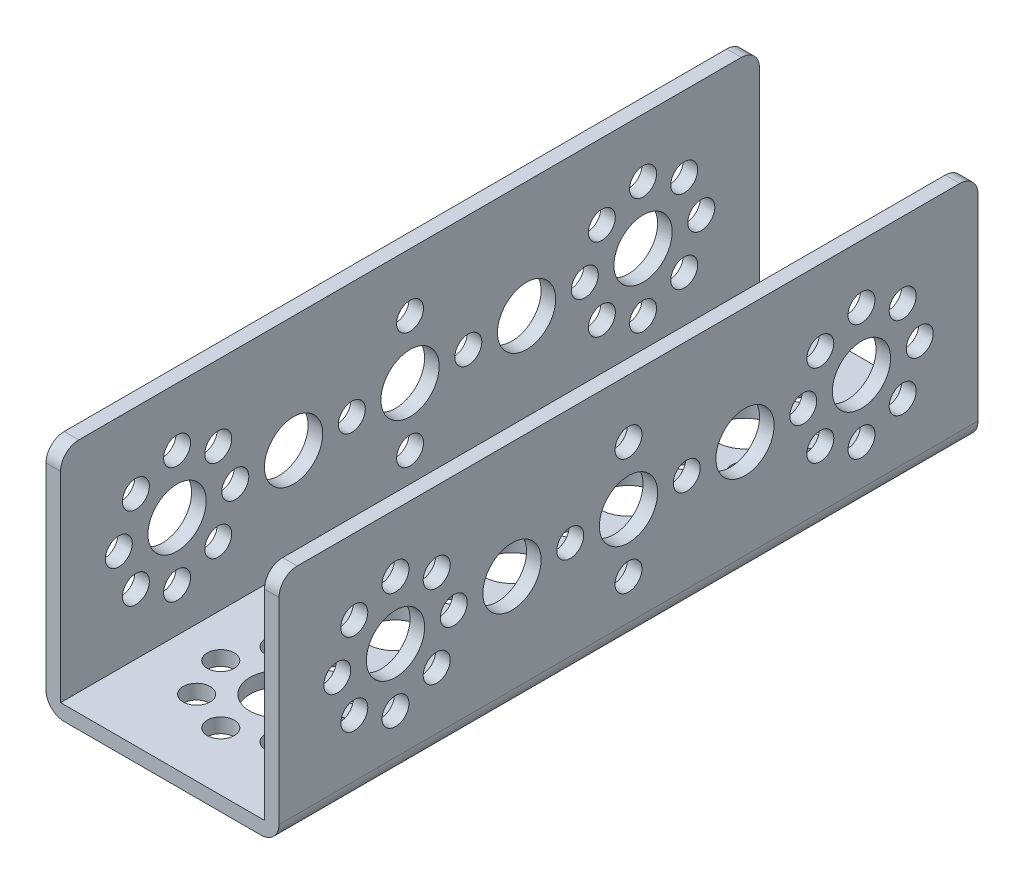
from build123d import *

# Parameters (mm, degrees)
SKETCH1_W                      = 96
SKETCH1_H                      = 32
BOSS_EXTRUDE1_DEPTH            = 32
SKETCH2_W                      = 28
SKETCH2_H                      = 30
CUT_EXTRUDE1_DEPTH             = 97
F_8_0_8_DIAMETER_HOLE1_D       = 8
F_8_0_8_DIAMETER_HOLE1_DEPTH   = 2
F_3_7_3_7_DIAMETER_HOLE1_D     = 3.7
F_3_7_3_7_DIAMETER_HOLE1_DEPTH = 2
F_3_7_3_7_DIAMETER_HOLE2_D     = 3.7
F_3_7_3_7_DIAMETER_HOLE2_DEPTH = 32
F_8_0_8_DIAMETER_HOLE2_D       = 8
F_8_0_8_DIAMETER_HOLE2_DEPTH   = 32
F_8_0_8_DIAMETER_HOLE3_D       = 8
F_8_0_8_DIAMETER_HOLE3_DEPTH   = 2
F_8_0_8_DIAMETER_HOLE4_D       = 8
F_8_0_8_DIAMETER_HOLE4_DEPTH   = 32
F_3_7_3_7_DIAMETER_HOLE3_D     = 3.7
F_3_7_3_7_DIAMETER_HOLE3_DEPTH = 32
FILLET1_R                      = 2.5


with BuildPart() as part:
    # Sketch1 → Boss-Extrude1 (new body)
    with BuildSketch(Plane(origin=(16, 0, 0), x_dir=(0, 0, -1), z_dir=(1, 0, 0))):
        with Locations((32, 16)):
            Rectangle(SKETCH1_W, SKETCH1_H)
    extrude(amount=-BOSS_EXTRUDE1_DEPTH)

    # Sketch2 → Cut-Extrude1 (cut, through all)
    with BuildSketch(Plane(origin=(0, 0, -80), x_dir=(-1, 0, 0), z_dir=(0, 0, -1))):
        with Locations((0, 17)):
            Rectangle(SKETCH2_W, SKETCH2_H)
    extrude(amount=-CUT_EXTRUDE1_DEPTH, mode=Mode.SUBTRACT)

    # Ø8.0 (8) Diameter Hole1
    with Locations(Plane.ZY.offset(16)):
        with Locations((-64, 16), (-32, 16), (-16, 16), (-48, 16), (0, 16)):
            Hole(F_8_0_8_DIAMETER_HOLE1_D / 2, depth=F_8_0_8_DIAMETER_HOLE1_DEPTH)

    # Ø3.7 (3.7) Diameter Hole1
    with Locations(Plane.ZY.offset(16)):
        with Locations((0, 24), (0, 8), (-8, 16), (8, 16), (-5.656854249, 21.656854249), (5.656854249, 21.656854249), (5.656854249, 10.343145751), (-5.656854249, 10.343145751), (-64, 24), (-64, 8), (-72, 16), (-56, 16), (-69.656854249, 21.656854249), (-58.343145751, 21.656854249), (-58.343145751, 10.343145751), (-69.656854249, 10.343145751), (-32, 24), (-40, 16), (-32, 8), (-24, 16)):
            Hole(F_3_7_3_7_DIAMETER_HOLE1_D / 2, depth=F_3_7_3_7_DIAMETER_HOLE1_DEPTH)

    # Ø3.7 (3.7) Diameter Hole2
    with Locations(Plane(origin=(0, 0, 0), x_dir=(-1, 0, 0), z_dir=(0, -1, 0))):
        with Locations((8, 0), (5.656854249, 5.656854249), (0, 8), (-5.656854249, 5.656854249), (-8, 0), (-5.656854249, -5.656854249), (0, -8), (5.656854249, -5.656854249), (8, 64), (5.656854249, 69.656854249), (0, 72), (-5.656854249, 69.656854249), (-8, 64), (-5.656854249, 58.343145751), (0, 56), (5.656854249, 58.343145751), (8, 32), (0, 40), (-8, 32), (0, 24)):
            Hole(F_3_7_3_7_DIAMETER_HOLE2_D / 2, depth=F_3_7_3_7_DIAMETER_HOLE2_DEPTH)

    # Ø8.0 (8) Diameter Hole2
    with Locations(Plane(origin=(0, 0, 0), x_dir=(-1, 0, 0), z_dir=(0, -1, 0))):
        with Locations((0, 0), (0, 64), (0, 32), (0, 16), (0, 48)):
            Hole(F_8_0_8_DIAMETER_HOLE2_D / 2, depth=F_8_0_8_DIAMETER_HOLE2_DEPTH)

    # Ø8.0 (8) Diameter Hole3
    with Locations(Plane.ZY.offset(-14)):
        with Locations((-32, 16)):
            Hole(F_8_0_8_DIAMETER_HOLE3_D / 2, depth=F_8_0_8_DIAMETER_HOLE3_DEPTH)

    # Ø8.0 (8) Diameter Hole4
    with Locations(Plane(origin=(16, 0, 0), x_dir=(0, 0, -1), z_dir=(1, 0, 0))):
        with Locations((64, 16), (16, 16), (48, 16), (0, 16)):
            Hole(F_8_0_8_DIAMETER_HOLE4_D / 2, depth=F_8_0_8_DIAMETER_HOLE4_DEPTH)

    # Ø3.7 (3.7) Diameter Hole3
    with Locations(Plane(origin=(16, 0, 0), x_dir=(0, 0, -1), z_dir=(1, 0, 0))):
        with Locations((0, 24), (0, 8), (8, 16), (-8, 16), (5.656854249, 21.656854249), (-5.656854249, 21.656854249), (-5.656854249, 10.343145751), (5.656854249, 10.343145751), (64, 24), (64, 8), (72, 16), (56, 16), (69.656854249, 21.656854249), (58.343145751, 21.656854249), (58.343145751, 10.343145751), (69.656854249, 10.343145751), (32, 24), (40, 16), (32, 8), (24, 16)):
            Hole(F_3_7_3_7_DIAMETER_HOLE3_D / 2, depth=F_3_7_3_7_DIAMETER_HOLE3_DEPTH)

    # Fillet1
    fillet1_edges = [part.edges().sort_by_distance(p)[0] for p in [
        (-16, 0, -32),
        (15, 32, 16),
        (15, 32, -80),
        (16, 0, -32),
        (-15, 32, -80),
        (-15, 32, 16),
    ]]
    fillet(fillet1_edges, radius=FILLET1_R)


solid = part.part
